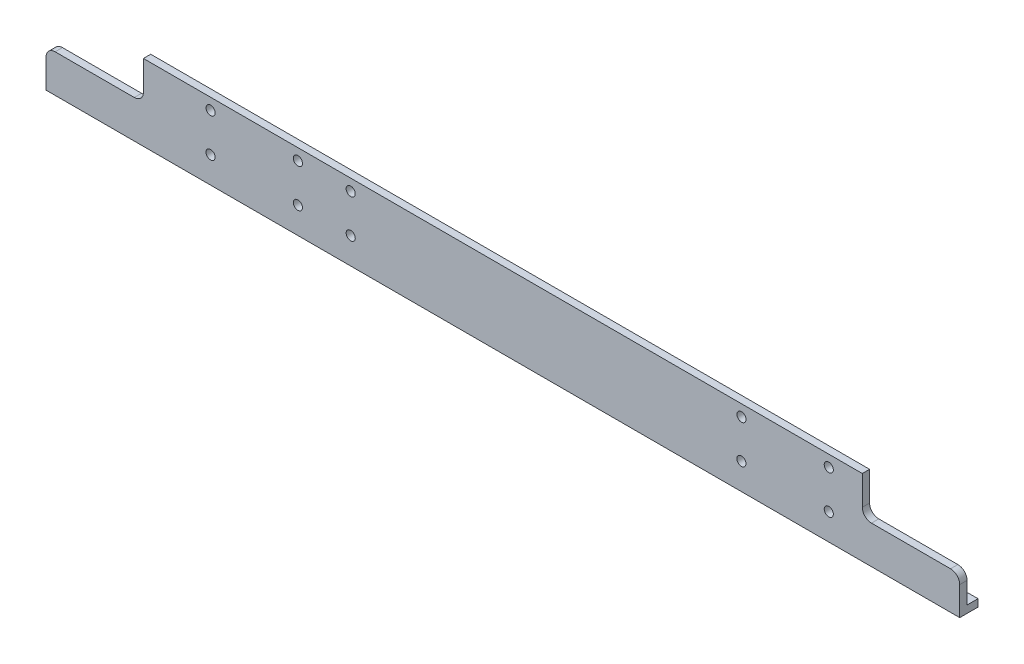
from build123d import *

# Parameters (mm, degrees)
BOSS_EXTRUDE1_DEPTH     = 190.5
F_6_CLEARANCE_HOLE1_D   = 3.7973
CUT_EXTRUDE1_DEPTH      = 196.720144594
CUT_EXTRUDE2_DEPTH      = 196.720144594
CUT_EXTRUDE2_DEPTH_BACK = 196.720144594
SKETCH6_W               = 25.4
SKETCH6_H               = 15.24
F_6_CLEARANCE_HOLE2_D   = 3.7973


with BuildPart() as part:
    # Sketch1 → Boss-Extrude1 (new, symmetric)
    with BuildSketch(Plane(origin=(0, 0, 0), x_dir=(0, 0, -1), z_dir=(1, 0, 0))):
        Polygon((0, 0), (31.75, 0), (31.75, 3.048), (3.048, 3.048), (3.048, 31.75), (0, 31.75), align=None)
    extrude(amount=BOSS_EXTRUDE1_DEPTH, both=True)

    # 6 Clearance Hole1 (through all)
    with Locations(Plane.XY):
        with Locations((135.9, 27), (135.9, 11), (99.5, 27), (99.468, 11), (-121.868, 27), (-121.868, 11), (-85.468, 11), (-85.468, 27)):
            Hole(F_6_CLEARANCE_HOLE1_D / 2)

    # Sketch5 → Cut-Extrude1 (cut, through all)
    with BuildSketch(Plane.XY):
        with BuildLine():
            Line((149.877, 41.148), (149.877, 19.558))
            ThreePointArc((149.877, 19.558), (150.992923164, 16.863923164), (153.687, 15.748))
            Line((153.687, 15.748), (186.69, 15.748))
            ThreePointArc((186.69, 15.748), (189.384076836, 14.632076836), (190.5, 11.938))
            Line((190.5, 11.938), (190.5, -9.652))
            Line((190.5, -9.652), (198.12, -9.652))
            Line((198.12, -9.652), (198.12, 41.148))
            Line((198.12, 41.148), (149.877, 41.148))
        make_face()
        with BuildLine():
            Line((-198.12, 41.148), (-149.877, 41.148))
            Line((-149.877, 41.148), (-149.877, 19.558))
            ThreePointArc((-149.877, 19.558), (-150.992923164, 16.863923164), (-153.687, 15.748))
            Line((-153.687, 15.748), (-186.69, 15.748))
            ThreePointArc((-186.69, 15.748), (-189.384076836, 14.632076836), (-190.5, 11.938))
            Line((-190.5, 11.938), (-190.5, -9.652))
            Line((-190.5, -9.652), (-198.12, -9.652))
            Line((-198.12, -9.652), (-198.12, 41.148))
        make_face()
    extrude(amount=-CUT_EXTRUDE1_DEPTH, mode=Mode.SUBTRACT)

    # Sketch6 → Cut-Extrude2 (cut, two sides: drawn at the far end of the back side and taken through both)
    with BuildSketch(Plane(origin=(0, 0, 0), x_dir=(0, 0, -1), z_dir=(1, 0, 0)).offset(-CUT_EXTRUDE2_DEPTH_BACK)):
        with Locations((20.32, 0)):
            Rectangle(SKETCH6_W, SKETCH6_H)
    extrude(amount=CUT_EXTRUDE2_DEPTH + CUT_EXTRUDE2_DEPTH_BACK, mode=Mode.SUBTRACT)

    # 6 Clearance Hole2 (through all)
    with Locations(Plane.XY):
        with Locations((-63.448, 27), (-63.448, 11)):
            Hole(F_6_CLEARANCE_HOLE2_D / 2)


solid = part.part
